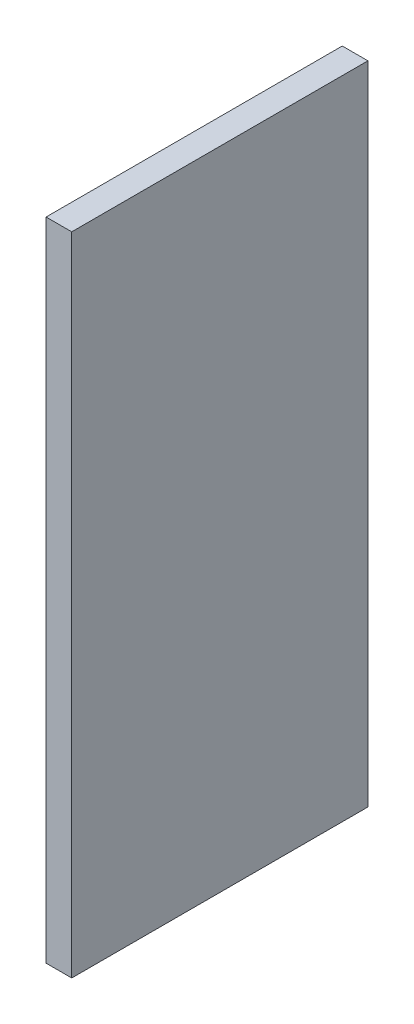
from build123d import *

# Parameters (mm, degrees)
SKETCH1_W           = 55
SKETCH1_H           = 120
BOSS_EXTRUDE1_DEPTH = 4.7625


with BuildPart() as part:
    # Sketch1 → Boss-Extrude1 (new body)
    with BuildSketch(Plane(origin=(0, 0, 0), x_dir=(0, 0, -1), z_dir=(1, 0, 0))):
        Rectangle(SKETCH1_W, SKETCH1_H)
    extrude(amount=BOSS_EXTRUDE1_DEPTH)


solid = part.part
